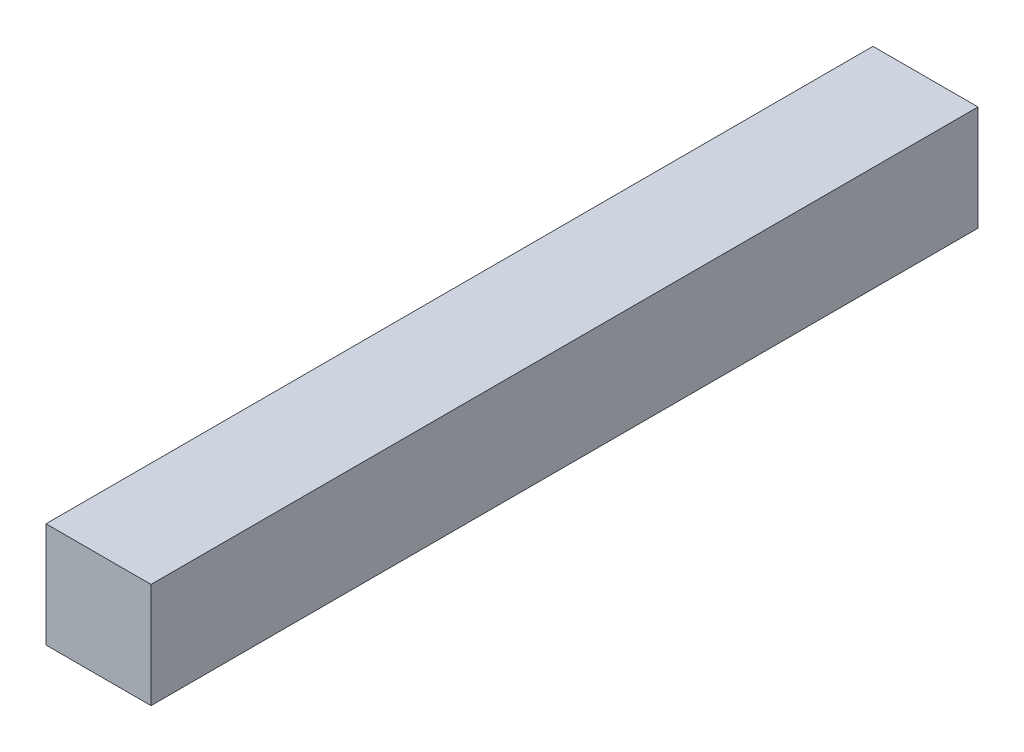
from build123d import *

# Parameters (mm, degrees)
SKETCH1_W           = 3.175
SKETCH1_H           = 3.175
BOSS_EXTRUDE1_DEPTH = 25


with BuildPart() as part:
    # Sketch1 → Boss-Extrude1 (new body)
    with BuildSketch(Plane.XY):
        Rectangle(SKETCH1_W, SKETCH1_H)
    extrude(amount=BOSS_EXTRUDE1_DEPTH)


solid = part.part
